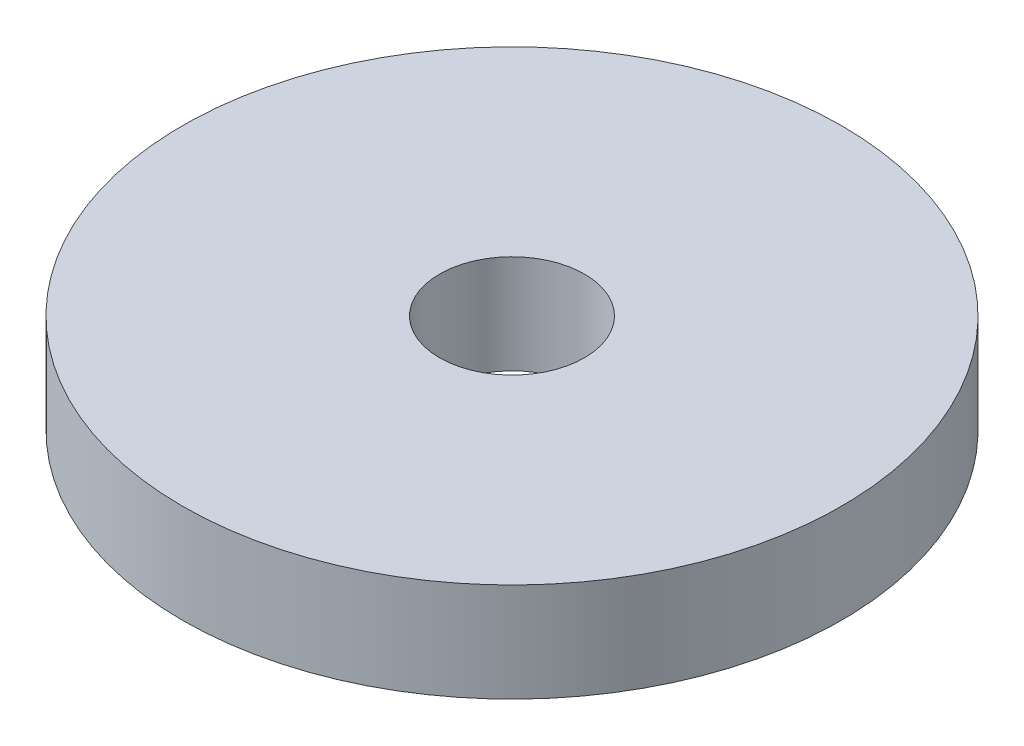
from build123d import *

# Parameters (mm, degrees)
SKETCH1_R           = 5
SKETCH1_R_2         = 1.1
BOSS_EXTRUDE1_DEPTH = 1.5


with BuildPart() as part:
    # Sketch1 → Boss-Extrude1 (new body)
    with BuildSketch(Plane(origin=(0, 0, 0), x_dir=(1, 0, 0), z_dir=(0, 1, 0))):
        Circle(SKETCH1_R)
        Circle(SKETCH1_R_2, mode=Mode.SUBTRACT)
    extrude(amount=BOSS_EXTRUDE1_DEPTH)


solid = part.part
